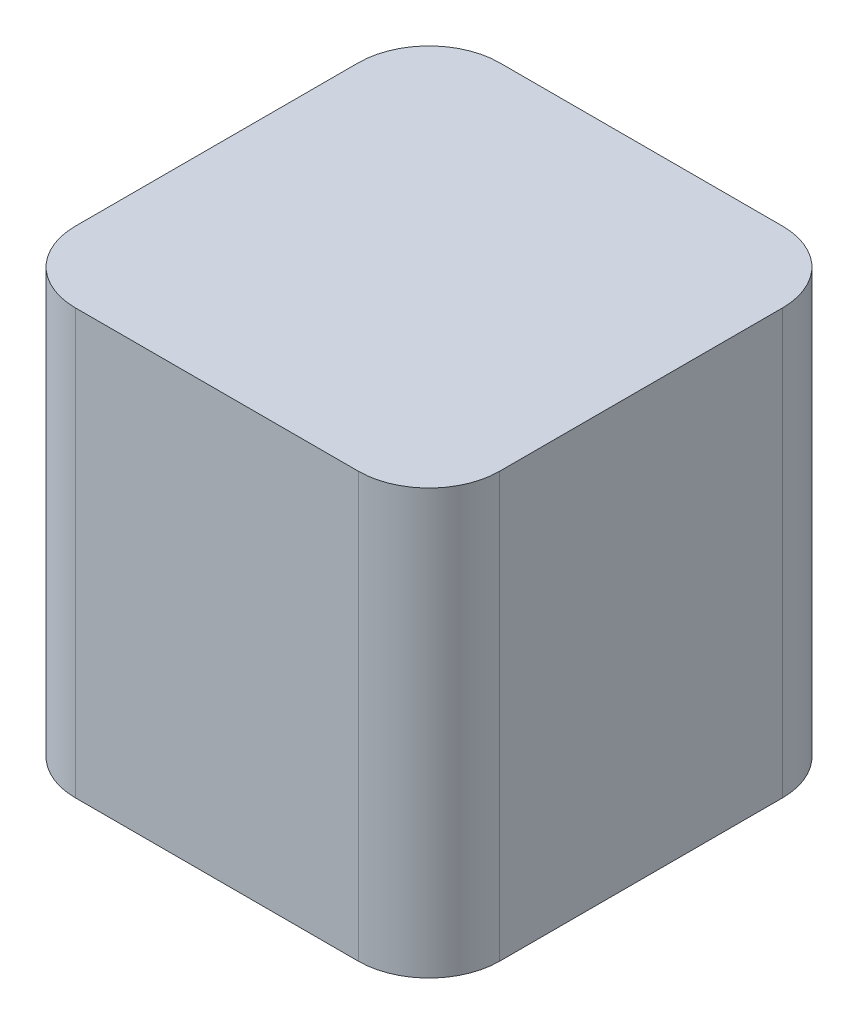
from build123d import *

# Parameters (mm, degrees)
SKETCH1_W           = 30
SKETCH1_H           = 30
BOSS_EXTRUDE1_DEPTH = 30
FILLET1_R           = 5
FILLET2_R           = 5
FILLET3_R           = 5
FILLET4_R           = 5


with BuildPart() as part:
    # Sketch1 → Boss-Extrude1 (new body)
    with BuildSketch(Plane(origin=(0, 0, 0), x_dir=(1, 0, 0), z_dir=(0, 1, 0))):
        Rectangle(SKETCH1_W, SKETCH1_H)
    extrude(amount=BOSS_EXTRUDE1_DEPTH)

    # Fillet1
    fillet1_edges = [part.edges().sort_by_distance(p)[0] for p in [
        (15, 15, 15),
    ]]
    fillet(fillet1_edges, radius=FILLET1_R)

    # Fillet2
    fillet2_edges = [part.edges().sort_by_distance(p)[0] for p in [
        (15, 15, -15),
    ]]
    fillet(fillet2_edges, radius=FILLET2_R)

    # Fillet3
    fillet3_edges = [part.edges().sort_by_distance(p)[0] for p in [
        (-15, 15, 15),
    ]]
    fillet(fillet3_edges, radius=FILLET3_R)

    # Fillet4
    fillet4_edges = [part.edges().sort_by_distance(p)[0] for p in [
        (-15, 15, -15),
    ]]
    fillet(fillet4_edges, radius=FILLET4_R)


solid = part.part
